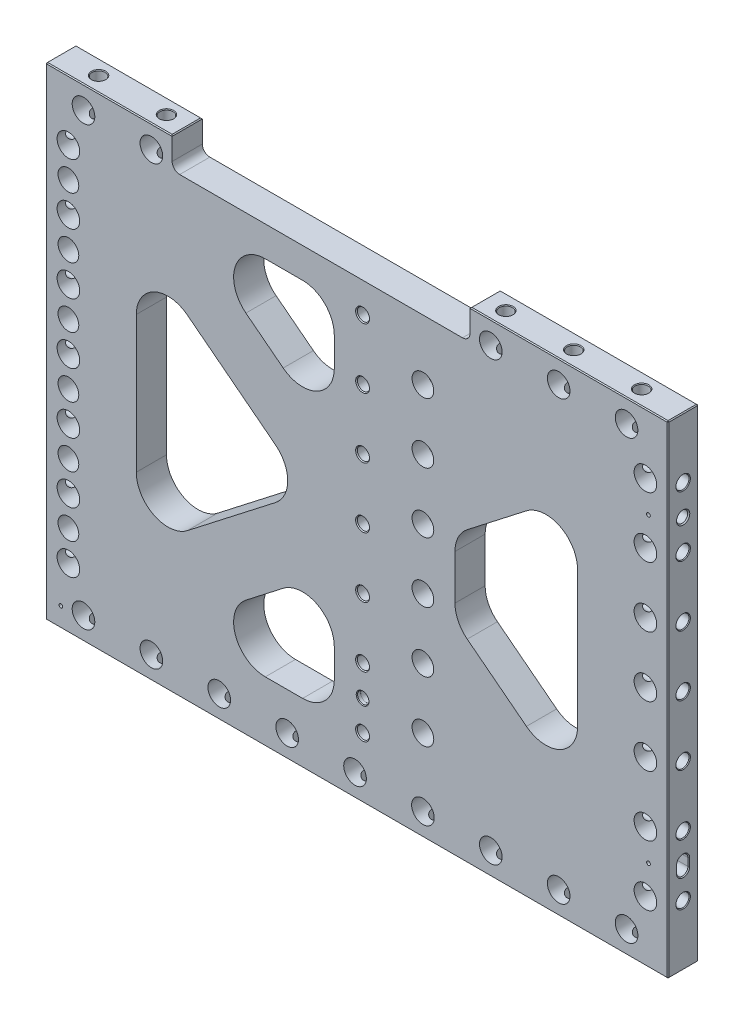
from build123d import *

# Parameters (mm, degrees)
SKETCH2_W                                     = 523.875
SKETCH2_H                                     = 406.4
EXTRUDE1_DEPTH                                = 12.7
TRIANGLES_CUT_EXTRUDE2_DEPTH                  = 26.4
TRIANGLES_FILLET1_R                           = 26.67
SKETCH14_W                                    = 38.1
SKETCH14_H                                    = 406.4
EXTRUDE3_DEPTH                                = 25.4
FILLET1_R                                     = 26.67
F_3_4_0_75_DIAMETER_HOLE1_D                   = 19.05
LPATTERN3_COUNT                               = 4
LPATTERN3_PITCH                               = 50.8
LPATTERN3_COL_COUNT                           = 4
LPATTERN3_COL_PITCH                           = 50.8
MIRROR1_COPY_1_D                              = 19.05
MIRROR1_COPY_2_D                              = 19.05
MIRROR1_COPY_3_D                              = 19.05
MIRROR1_COPY_7_D                              = 19.05
MIRROR1_COPY_8_D                              = 19.05
MIRROR1_COPY_9_D                              = 19.05
F_3_4_0_75_DIAMETER_HOLE2_D                   = 19.05
LPATTERN4_COUNT                               = 9
LPATTERN4_PITCH                               = 57.15
F_3_4_0_75_DIAMETER_HOLE3_D                   = 19.05
LPATTERN6_COUNT                               = 9
LPATTERN6_PITCH                               = 57.15
LPATTERN5_COUNT                               = 4
LPATTERN5_PITCH                               = 50.8
LPATTERN5_COL_COUNT                           = 4
LPATTERN5_COL_PITCH                           = 50.8
CBORE_FOR_3_8_SOCKET_HEAD_CAP_SCREW1_AT_COUNT = 2
CBORE_FOR_3_8_SOCKET_HEAD_CAP_SCREW1_AT_PITCH = 50.8
CBORE_FOR_3_8_SOCKET_HEAD_CAP_SCREW1_2_COUNT  = 2
CBORE_FOR_3_8_SOCKET_HEAD_CAP_SCREW1_2_PITCH  = 101.6
CBORE_FOR_3_8_SOCKET_HEAD_CAP_SCREW1_3_COUNT  = 2
CBORE_FOR_3_8_SOCKET_HEAD_CAP_SCREW1_3_PITCH  = 152.4
CBORE_FOR_3_8_SOCKET_HEAD_CAP_SCREW1_4_COUNT  = 2
CBORE_FOR_3_8_SOCKET_HEAD_CAP_SCREW1_4_PITCH  = 203.2
CBORE_FOR_3_8_SOCKET_HEAD_CAP_SCREW1_5_COUNT  = 2
CBORE_FOR_3_8_SOCKET_HEAD_CAP_SCREW1_5_PITCH  = 254
SKETCH19_W                                    = 250.7996
SKETCH19_H                                    = 25.4
CUT_EXTRUDE1_DEPTH                            = 25.4
FILLET2_R                                     = 6.35
EXTRUDE5_DEPTH                                = 25.4
FILLET3_R                                     = 26.67
CBORE_FOR_3_8_SOCKET_AT_2_COUNT               = 2
CBORE_FOR_3_8_SOCKET_AT_2_PITCH               = 50.8
CBORE_FOR_3_8_SOCKET_AT_3_COUNT               = 2
CBORE_FOR_3_8_SOCKET_AT_3_PITCH               = 101.6
CBORE_FOR_3_8_SOCKET_AT_4_COUNT               = 2
CBORE_FOR_3_8_SOCKET_AT_4_PITCH               = 152.4
CBORE_FOR_3_8_SOCKET_AT_5_COUNT               = 2
CBORE_FOR_3_8_SOCKET_AT_5_PITCH               = 203.2
CBORE_FOR_3_8_SOCKET_AT_6_COUNT               = 2
CBORE_FOR_3_8_SOCKET_AT_6_PITCH               = 254
F_3_8_0_376_PIN_LOCATE1_D                     = 9.5504
F_3_8_0_376_PIN_LOCATE1_DEPTH                 = 19.05
F_3_8_0_376_PIN_LOCATE1_CSINK_D               = 11.176
F_3_8_0_376_PIN_LOCATE1_CSINK_ANGLE           = 82
F_3_8_0_376_PIN_LOCATE1_TIP                   = 2.869229628
SLOT_LOCATE1_DEPTH                            = 19.05
CHAMFER1_SIZE                                 = 0.762
F_1_8_0_125_DIAMETER_HOLE1_D                  = 3.175
F_1_8_0_125_DIAMETER_HOLE1_DEPTH              = 9.652
F_1_8_0_125_DIAMETER_HOLE1_TIP                = 0.953866233
CHAMFER2_SIZE                                 = 0.762


with BuildPart() as part:
    # Sketch2 → Extrude1 (new body, symmetric)
    with BuildSketch(Plane.XY):
        Rectangle(SKETCH2_W, SKETCH2_H)
    extrude(amount=EXTRUDE1_DEPTH, both=True)

    # Sketch8 → Triangles -- Cut-Extrude2 (cut, through all)
    with BuildSketch(Plane.XY.offset(12.7)):
        Polygon((-185.7375, 111.940466206), (-41.439242781, 0), (-185.7375, -111.940466206), align=None)
        Polygon((-155.013882219, 152.4), (0, 32.146806521), (155.013882219, 152.4), align=None)
        Polygon((185.7375, 111.940466206), (185.7375, -111.940466206), (41.439242781, 0), align=None)
        Polygon((0, -32.146806521), (-155.013882219, -152.4), (155.013882219, -152.4), align=None)
    extrude(amount=-TRIANGLES_CUT_EXTRUDE2_DEPTH, mode=Mode.SUBTRACT)

    # Triangles -- Fillet1
    triangles_fillet1_edges = [part.edges().sort_by_distance(p)[0] for p in [
        (-185.7375, -111.940466206, 0),
        (-185.7375, 111.940466206, 0),
        (-41.439242781, 0, 0),
        (-155.013882219, 152.4, 0),
        (155.013882219, 152.4, 0),
        (0, 32.146806521, 0),
        (41.439242781, 0, 0),
        (185.7375, 111.940466206, 0),
        (185.7375, -111.940466206, 0),
        (0, -32.146806521, 0),
        (155.013882219, -152.4, 0),
        (-155.013882219, -152.4, 0),
    ]]
    fillet(triangles_fillet1_edges, radius=TRIANGLES_FILLET1_R)

    # Sketch14 → Extrude3 (add, through all)
    with BuildSketch(Plane.XY.offset(12.7)):
        Rectangle(SKETCH14_W, SKETCH14_H)
    extrude(amount=-EXTRUDE3_DEPTH)

    # Fillet1
    fillet1_edges = [part.edges().sort_by_distance(p)[0] for p in [
        (-19.05, -46.924988339, 0),
        (19.05, -152.4, 0),
        (19.05, 152.4, 0),
        (19.05, 46.924988339, 0),
        (19.05, -46.924988339, 0),
        (-19.05, 152.4, 0),
        (-19.05, -152.4, 0),
        (-19.05, 46.924988339, 0),
    ]]
    fillet(fillet1_edges, radius=FILLET1_R)

    # 3/4 (0.75) Diameter Hole1 (through all)
    with Locations(Plane.XY.offset(12.7)):
        with Locations((-242.8875, 0)):
            f_3_4_0_75_diameter_hole1 = Hole(F_3_4_0_75_DIAMETER_HOLE1_D / 2)

    # Sketch5 → 7/16 (0.4375) Diameter Hole1 (revolve, cut)
    with BuildSketch(Plane(origin=(-261.9375, 0, 0), x_dir=(0, 0, 1), z_dir=(0, 1, 0))):
        Polygon((0, 0), (0, 38.263531814), (5.55625, 34.925), (5.55625, 0.620911348), (6.096, 0), align=None)
    f_7_16_0_4375_diameter_hole1 = revolve(axis=Axis((-268.2875, 0, 0), (1, 0, 0)), mode=Mode.SUBTRACT)

    # LPattern3: 3/4 (0.75) Diameter Hole1, 7/16 (0.4375) Diameter Hole1 ×4
    with Locations(*[(0, i * LPATTERN3_PITCH, 0) for i in range(1, LPATTERN3_COUNT)]):
        add(f_3_4_0_75_diameter_hole1, mode=Mode.SUBTRACT)
        add(f_7_16_0_4375_diameter_hole1, mode=Mode.SUBTRACT)

    # LPattern3 col: 3/4 (0.75) Diameter Hole1, 7/16 (0.4375) Diameter Hole1 ×4
    with Locations(*[(0, -i * LPATTERN3_COL_PITCH, 0) for i in range(1, LPATTERN3_COL_COUNT)]):
        add(f_3_4_0_75_diameter_hole1, mode=Mode.SUBTRACT)
        add(f_7_16_0_4375_diameter_hole1, mode=Mode.SUBTRACT)

    # Mirror1: 3/4 (0.75) Diameter Hole1, 7/16 (0.4375) Diameter Hole1 across plane
    add(f_3_4_0_75_diameter_hole1.mirror(Plane(origin=(0, 0, 0), x_dir=(0, 0, 1), z_dir=(1, 0, 0))), mode=Mode.SUBTRACT)
    add(f_7_16_0_4375_diameter_hole1.mirror(Plane(origin=(0, 0, 0), x_dir=(0, 0, 1), z_dir=(1, 0, 0))), mode=Mode.SUBTRACT)

    # Mirror1 copy 1 (through all)
    with Locations(Plane(origin=(0, 50.8, 12.7), x_dir=(-1, 0, 0), z_dir=(0, 0, 1))):
        with Locations((-242.8875, 0)):
            Hole(MIRROR1_COPY_1_D / 2)

    # Mirror1 copy 2 (through all)
    with Locations(Plane(origin=(0, 101.6, 12.7), x_dir=(-1, 0, 0), z_dir=(0, 0, 1))):
        with Locations((-242.8875, 0)):
            Hole(MIRROR1_COPY_2_D / 2)

    # Mirror1 copy 3 (through all)
    with Locations(Plane(origin=(0, 152.4, 12.7), x_dir=(-1, 0, 0), z_dir=(0, 0, 1))):
        with Locations((-242.8875, 0)):
            Hole(MIRROR1_COPY_3_D / 2)

    # Mirror1 copy 4 sketch → Mirror1 copy 4 (revolve, cut)
    with BuildSketch(Plane(origin=(261.9375, 50.8, 0), x_dir=(0, 0, 1), z_dir=(0, 1, 0))):
        Polygon((0, 0), (0, -38.263531814), (5.55625, -34.925), (5.55625, -0.620911348), (6.096, 0), align=None)
    revolve(axis=Axis((268.2875, 50.8, 0), (1, 0, 0)), mode=Mode.SUBTRACT)

    # Mirror1 copy 5 sketch → Mirror1 copy 5 (revolve, cut)
    with BuildSketch(Plane(origin=(261.9375, 101.6, 0), x_dir=(0, 0, 1), z_dir=(0, 1, 0))):
        Polygon((0, 0), (0, -38.263531814), (5.55625, -34.925), (5.55625, -0.620911348), (6.096, 0), align=None)
    revolve(axis=Axis((268.2875, 101.6, 0), (1, 0, 0)), mode=Mode.SUBTRACT)

    # Mirror1 copy 6 sketch → Mirror1 copy 6 (revolve, cut)
    with BuildSketch(Plane(origin=(261.9375, 152.4, 0), x_dir=(0, 0, 1), z_dir=(0, 1, 0))):
        Polygon((0, 0), (0, -38.263531814), (5.55625, -34.925), (5.55625, -0.620911348), (6.096, 0), align=None)
    revolve(axis=Axis((268.2875, 152.4, 0), (1, 0, 0)), mode=Mode.SUBTRACT)

    # Mirror1 copy 7 (through all)
    with Locations(Plane(origin=(0, -50.8, 12.7), x_dir=(-1, 0, 0), z_dir=(0, 0, 1))):
        with Locations((-242.8875, 0)):
            Hole(MIRROR1_COPY_7_D / 2)

    # Mirror1 copy 8 (through all)
    with Locations(Plane(origin=(0, -101.6, 12.7), x_dir=(-1, 0, 0), z_dir=(0, 0, 1))):
        with Locations((-242.8875, 0)):
            Hole(MIRROR1_COPY_8_D / 2)

    # Mirror1 copy 9 (through all)
    with Locations(Plane(origin=(0, -152.4, 12.7), x_dir=(-1, 0, 0), z_dir=(0, 0, 1))):
        with Locations((-242.8875, 0)):
            Hole(MIRROR1_COPY_9_D / 2)

    # Mirror1 copy 10 sketch → Mirror1 copy 10 (revolve, cut)
    with BuildSketch(Plane(origin=(261.9375, -50.8, 0), x_dir=(0, 0, 1), z_dir=(0, 1, 0))):
        Polygon((0, 0), (0, -38.263531814), (5.55625, -34.925), (5.55625, -0.620911348), (6.096, 0), align=None)
    revolve(axis=Axis((268.2875, -50.8, 0), (1, 0, 0)), mode=Mode.SUBTRACT)

    # Mirror1 copy 11 sketch → Mirror1 copy 11 (revolve, cut)
    with BuildSketch(Plane(origin=(261.9375, -101.6, 0), x_dir=(0, 0, 1), z_dir=(0, 1, 0))):
        Polygon((0, 0), (0, -38.263531814), (5.55625, -34.925), (5.55625, -0.620911348), (6.096, 0), align=None)
    revolve(axis=Axis((268.2875, -101.6, 0), (1, 0, 0)), mode=Mode.SUBTRACT)

    # Mirror1 copy 12 sketch → Mirror1 copy 12 (revolve, cut)
    with BuildSketch(Plane(origin=(261.9375, -152.4, 0), x_dir=(0, 0, 1), z_dir=(0, 1, 0))):
        Polygon((0, 0), (0, -38.263531814), (5.55625, -34.925), (5.55625, -0.620911348), (6.096, 0), align=None)
    revolve(axis=Axis((268.2875, -152.4, 0), (1, 0, 0)), mode=Mode.SUBTRACT)

    # 3/4 (0.75) Diameter Hole2 (through all)
    with Locations(Plane.XY.offset(12.7)):
        with Locations((-230.1875, -184.15)):
            f_3_4_0_75_diameter_hole2 = Hole(F_3_4_0_75_DIAMETER_HOLE2_D / 2)

    # Sketch12 → 7/16 (0.4375) Diameter Hole2 (revolve, cut)
    with BuildSketch(Plane(origin=(-230.1875, -203.2, 0), x_dir=(0, 0, -1), z_dir=(1, 0, 0))):
        Polygon((0, 0), (0, 38.263531814), (5.55625, 34.925), (5.55625, 0.620911348), (6.096, 0), align=None)
    f_7_16_0_4375_diameter_hole2 = revolve(axis=Axis((-230.1875, -209.55, 0), (0, 1, 0)), mode=Mode.SUBTRACT)

    # LPattern4: 3/4 (0.75) Diameter Hole2, 7/16 (0.4375) Diameter Hole2 ×9
    with Locations(*[(i * LPATTERN4_PITCH, 0, 0) for i in range(1, LPATTERN4_COUNT)]):
        add(f_3_4_0_75_diameter_hole2, mode=Mode.SUBTRACT)
        add(f_7_16_0_4375_diameter_hole2, mode=Mode.SUBTRACT)

    # 3/4 (0.75) Diameter Hole3 (through all)
    with Locations(Plane.XY.offset(12.7)):
        with Locations((-230.1875, 184.15)):
            f_3_4_0_75_diameter_hole3 = Hole(F_3_4_0_75_DIAMETER_HOLE3_D / 2)

    # Sketch35 → 7/16 (0.4375) Diameter Hole3 (revolve, cut)
    with BuildSketch(Plane(origin=(-230.1875, 203.2, 0), x_dir=(0, 0, 1), z_dir=(1, 0, 0))):
        Polygon((0, 0), (0, 38.263531814), (5.55625, 34.925), (5.55625, 0.620911348), (6.096, 0), align=None)
    f_7_16_0_4375_diameter_hole3 = revolve(axis=Axis((-230.1875, 209.55, 0), (0, -1, 0)), mode=Mode.SUBTRACT)

    # LPattern6: 3/4 (0.75) Diameter Hole3, 7/16 (0.4375) Diameter Hole3 ×9, 4 skipped
    with Locations(*[(i * LPATTERN6_PITCH, 0, 0) for i in range(1, LPATTERN6_COUNT) if i not in (2, 3, 4, 5)]):
        add(f_3_4_0_75_diameter_hole3, mode=Mode.SUBTRACT)
        add(f_7_16_0_4375_diameter_hole3, mode=Mode.SUBTRACT)

    # Sketch15 → CBORE for 3/8 Socket Head Cap Screw2 (revolve, cut)
    with BuildSketch(Plane(origin=(4.7625, 0, -12.7), x_dir=(0, 1, 0), z_dir=(1, 0, 0))):
        Polygon((0, 0), (0, 25.4), (5.842, 25.4), (5.15874, 24.613999282), (5.15874, 10.668), (8.73125, 10.668), (8.73125, 0), align=None)
    cbore_for_3_8_socket_head_cap_screw2 = revolve(axis=Axis((4.7625, 0, -19.05), (0, 0, 1)), mode=Mode.SUBTRACT)

    # LPattern5: CBORE for 3/8 Socket Head Cap Screw2 ×4
    with Locations(*[(0, -i * LPATTERN5_PITCH, 0) for i in range(1, LPATTERN5_COUNT)]):
        add(cbore_for_3_8_socket_head_cap_screw2, mode=Mode.SUBTRACT)

    # LPattern5 col: CBORE for 3/8 Socket Head Cap Screw2 ×4
    with Locations(*[(0, i * LPATTERN5_COL_PITCH, 0) for i in range(1, LPATTERN5_COL_COUNT)]):
        add(cbore_for_3_8_socket_head_cap_screw2, mode=Mode.SUBTRACT)

    # Sketch17 → CBORE for 3/8 Socket Head Cap Screw1 (revolve, cut)
    with BuildSketch(Plane(origin=(-242.8875, 127, 12.7), x_dir=(0, -1, 0), z_dir=(1, 0, 0))):
        Polygon((0, 0), (0, 25.4), (5.842, 25.4), (5.15874, 24.613999282), (5.15874, 12.7), (8.73125, 12.7), (8.73125, 0), align=None)
    cbore_for_3_8_socket_head_cap_screw1 = revolve(axis=Axis((-242.8875, 127, 19.05), (0, 0, -1)), mode=Mode.SUBTRACT)

    # CBORE for 3/8 Socket Head Cap Screw1 at: CBORE for 3/8 Socket Head Cap Screw1 ×2
    with Locations(*[(0, -i * CBORE_FOR_3_8_SOCKET_HEAD_CAP_SCREW1_AT_PITCH, 0) for i in range(1, CBORE_FOR_3_8_SOCKET_HEAD_CAP_SCREW1_AT_COUNT)]):
        add(cbore_for_3_8_socket_head_cap_screw1, mode=Mode.SUBTRACT)

    # CBORE for 3/8 Socket Head Cap Screw1 2: CBORE for 3/8 Socket Head Cap Screw1 ×2
    with Locations(*[(0, -i * CBORE_FOR_3_8_SOCKET_HEAD_CAP_SCREW1_2_PITCH, 0) for i in range(1, CBORE_FOR_3_8_SOCKET_HEAD_CAP_SCREW1_2_COUNT)]):
        add(cbore_for_3_8_socket_head_cap_screw1, mode=Mode.SUBTRACT)

    # CBORE for 3/8 Socket Head Cap Screw1 3: CBORE for 3/8 Socket Head Cap Screw1 ×2
    with Locations(*[(0, -i * CBORE_FOR_3_8_SOCKET_HEAD_CAP_SCREW1_3_PITCH, 0) for i in range(1, CBORE_FOR_3_8_SOCKET_HEAD_CAP_SCREW1_3_COUNT)]):
        add(cbore_for_3_8_socket_head_cap_screw1, mode=Mode.SUBTRACT)

    # CBORE for 3/8 Socket Head Cap Screw1 4: CBORE for 3/8 Socket Head Cap Screw1 ×2
    with Locations(*[(0, -i * CBORE_FOR_3_8_SOCKET_HEAD_CAP_SCREW1_4_PITCH, 0) for i in range(1, CBORE_FOR_3_8_SOCKET_HEAD_CAP_SCREW1_4_COUNT)]):
        add(cbore_for_3_8_socket_head_cap_screw1, mode=Mode.SUBTRACT)

    # CBORE for 3/8 Socket Head Cap Screw1 5: CBORE for 3/8 Socket Head Cap Screw1 ×2
    with Locations(*[(0, -i * CBORE_FOR_3_8_SOCKET_HEAD_CAP_SCREW1_5_PITCH, 0) for i in range(1, CBORE_FOR_3_8_SOCKET_HEAD_CAP_SCREW1_5_COUNT)]):
        add(cbore_for_3_8_socket_head_cap_screw1, mode=Mode.SUBTRACT)

    # Sketch19 → Cut-Extrude1 (cut)
    with BuildSketch(Plane(origin=(0, 203.2, 0), x_dir=(1, 0, 0), z_dir=(0, 1, 0))):
        with Locations((-30.1625, 0)):
            Rectangle(SKETCH19_W, SKETCH19_H)
    extrude(amount=-CUT_EXTRUDE1_DEPTH, mode=Mode.SUBTRACT)

    # Fillet2
    fillet2_edges = [part.edges().sort_by_distance(p)[0] for p in [
        (95.2373, 177.8, 0),
        (-155.5623, 177.8, 0),
    ]]
    fillet(fillet2_edges, radius=FILLET2_R)

    # Sketch21 → Extrude5 (add, through all)
    with BuildSketch(Plane.XY.offset(12.7)):
        with BuildLine():
            Line((77.123380423, 152.4), (19.05, 152.4))
            Line((19.05, 152.4), (19.05, -152.4))
            Line((19.05, -152.4), (77.123380423, -152.4))
            ThreePointArc((77.123380423, -152.4), (102.355266417, -134.369492415), (93.470638591, -104.657362519))
            Line((93.470638591, -104.657362519), (82.55, -96.1855944))
            Line((82.55, -96.1855944), (82.55, 96.1855944))
            Line((82.55, 96.1855944), (93.470638591, 104.657362519))
            ThreePointArc((93.470638591, 104.657362519), (102.355266417, 134.369492415), (77.123380423, 152.4))
        make_face()
    extrude(amount=-EXTRUDE5_DEPTH)

    # Fillet3
    fillet3_edges = [part.edges().sort_by_distance(p)[0] for p in [
        (82.55, 31.891981358, 0),
        (82.55, -31.891981358, 0),
    ]]
    fillet(fillet3_edges, radius=FILLET3_R)

    # Sketch22 → CBORE for 3/8 Socket (revolve, cut)
    with BuildSketch(Plane(origin=(55.5625, 127, 12.7), x_dir=(0, -1, 0), z_dir=(1, 0, 0))):
        Polygon((0, 0), (0, 25.4), (6.35, 25.4), (5.55625, 24.486895077), (5.55625, 12.7), (9.128125, 12.7), (9.128125, 0), align=None)
    cbore_for_3_8_socket = revolve(axis=Axis((55.5625, 127, 19.05), (0, 0, -1)), mode=Mode.SUBTRACT)

    # CBORE for 3/8 Socket at 2: CBORE for 3/8 Socket ×2
    with Locations(*[(0, -i * CBORE_FOR_3_8_SOCKET_AT_2_PITCH, 0) for i in range(1, CBORE_FOR_3_8_SOCKET_AT_2_COUNT)]):
        add(cbore_for_3_8_socket, mode=Mode.SUBTRACT)

    # CBORE for 3/8 Socket at 3: CBORE for 3/8 Socket ×2
    with Locations(*[(0, -i * CBORE_FOR_3_8_SOCKET_AT_3_PITCH, 0) for i in range(1, CBORE_FOR_3_8_SOCKET_AT_3_COUNT)]):
        add(cbore_for_3_8_socket, mode=Mode.SUBTRACT)

    # CBORE for 3/8 Socket at 4: CBORE for 3/8 Socket ×2
    with Locations(*[(0, -i * CBORE_FOR_3_8_SOCKET_AT_4_PITCH, 0) for i in range(1, CBORE_FOR_3_8_SOCKET_AT_4_COUNT)]):
        add(cbore_for_3_8_socket, mode=Mode.SUBTRACT)

    # CBORE for 3/8 Socket at 5: CBORE for 3/8 Socket ×2
    with Locations(*[(0, -i * CBORE_FOR_3_8_SOCKET_AT_5_PITCH, 0) for i in range(1, CBORE_FOR_3_8_SOCKET_AT_5_COUNT)]):
        add(cbore_for_3_8_socket, mode=Mode.SUBTRACT)

    # CBORE for 3/8 Socket at 6: CBORE for 3/8 Socket ×2
    with Locations(*[(0, -i * CBORE_FOR_3_8_SOCKET_AT_6_PITCH, 0) for i in range(1, CBORE_FOR_3_8_SOCKET_AT_6_COUNT)]):
        add(cbore_for_3_8_socket, mode=Mode.SUBTRACT)

    # 3/8 (0.376) Pin Locate1
    with Locations(Plane(origin=(261.9375, 0, 0), x_dir=(0, 0, -1), z_dir=(1, 0, 0))):
        with Locations((0, 127)):
            CounterSinkHole(F_3_8_0_376_PIN_LOCATE1_D / 2, F_3_8_0_376_PIN_LOCATE1_CSINK_D / 2, depth=F_3_8_0_376_PIN_LOCATE1_DEPTH, counter_sink_angle=F_3_8_0_376_PIN_LOCATE1_CSINK_ANGLE)
            with Locations((0, 0, -(F_3_8_0_376_PIN_LOCATE1_DEPTH + F_3_8_0_376_PIN_LOCATE1_TIP / 2))):  # 118° drill point
                Cone(0, F_3_8_0_376_PIN_LOCATE1_D / 2, F_3_8_0_376_PIN_LOCATE1_TIP, mode=Mode.SUBTRACT)

    # Sketch26 → Slot Locate1 (cut)
    with BuildSketch(Plane(origin=(261.9375, 0, 0), x_dir=(0, 0, -1), z_dir=(1, 0, 0))):
        with BuildLine():
            Line((-4.7752, -123.825), (-4.7752, -130.175))
            ThreePointArc((-4.7752, -130.175), (0, -134.9502), (4.7752, -130.175))
            Line((4.7752, -130.175), (4.7752, -123.825))
            ThreePointArc((4.7752, -123.825), (0, -119.0498), (-4.7752, -123.825))
        make_face()
    extrude(amount=-SLOT_LOCATE1_DEPTH, mode=Mode.SUBTRACT)

    # Chamfer1
    chamfer1_edges = [part.edges().sort_by_distance(p)[0] for p in [
        (261.9375, -119.0498, 0),
        (261.9375, -127, 4.7752),
        (261.9375, -134.9502, 0),
        (261.9375, -127, -4.7752),
    ]]
    chamfer(chamfer1_edges, length=CHAMFER1_SIZE)

    # Sketch27 → 3/8 (0.375) Pin + Lead-In Hole1 (revolve, cut)
    with BuildSketch(Plane(origin=(-249.2375, -203.2, 0), x_dir=(0, 0, -1), z_dir=(1, 0, 0))):
        Polygon((0, 0), (0, 21.911598698), (4.7625, 19.05), (4.7625, 3.175), (4.7879, 3.175), (4.7879, 0.628216187), (5.334, 0), align=None)
    revolve(axis=Axis((-249.2375, -209.55, 0), (0, 1, 0)), mode=Mode.SUBTRACT)

    # 1/8 (0.125) Diameter Hole1
    with Locations(Plane.XY.offset(12.7)):
        with Locations((-249.2375, -186.69), (245.4275, -127), (245.4275, 127)):
            Hole(F_1_8_0_125_DIAMETER_HOLE1_D / 2, depth=F_1_8_0_125_DIAMETER_HOLE1_DEPTH)
            with Locations((0, 0, -(F_1_8_0_125_DIAMETER_HOLE1_DEPTH + F_1_8_0_125_DIAMETER_HOLE1_TIP / 2))):  # 118° drill point
                Cone(0, F_1_8_0_125_DIAMETER_HOLE1_D / 2, F_1_8_0_125_DIAMETER_HOLE1_TIP, mode=Mode.SUBTRACT)

    # Sketch31 → 3/8 (0.375) Pin + Lead-In Hole2 (revolve, cut)
    with BuildSketch(Plane(origin=(4.7625, -127, 12.7), x_dir=(0, -1, 0), z_dir=(1, 0, 0))):
        Polygon((0, 0), (0, 25.4), (4.7625, 25.4), (4.7625, 3.175), (4.7879, 3.175), (4.7879, 0.628216187), (5.334, 0), align=None)
    revolve(axis=Axis((4.7625, -127, 19.05), (0, 0, -1)), mode=Mode.SUBTRACT)

    # Chamfer2
    chamfer2_edges = [part.edges().sort_by_distance(p)[0] for p in [
        (261.9375, 0, 12.7),
        (178.5874, 203.2, 12.7),
        (-261.9375, 0, 12.7),
        (178.5874, 203.2, -12.7),
        (261.9375, 0, -12.7),
        (0, -203.2, -12.7),
        (-261.9375, 0, -12.7),
        (-208.7499, 203.2, -12.7),
        (-208.7499, 203.2, 12.7),
        (95.2373, 203.2, 0),
        (-155.5623, 203.2, 0),
        (0, -203.2, 12.7),
        (-261.9375, 203.2, 0),
        (261.9375, 203.2, 0),
        (261.9375, -203.2, 0),
        (-261.9375, -203.2, 0),
    ]]
    chamfer(chamfer2_edges, length=CHAMFER2_SIZE)


solid = part.part
